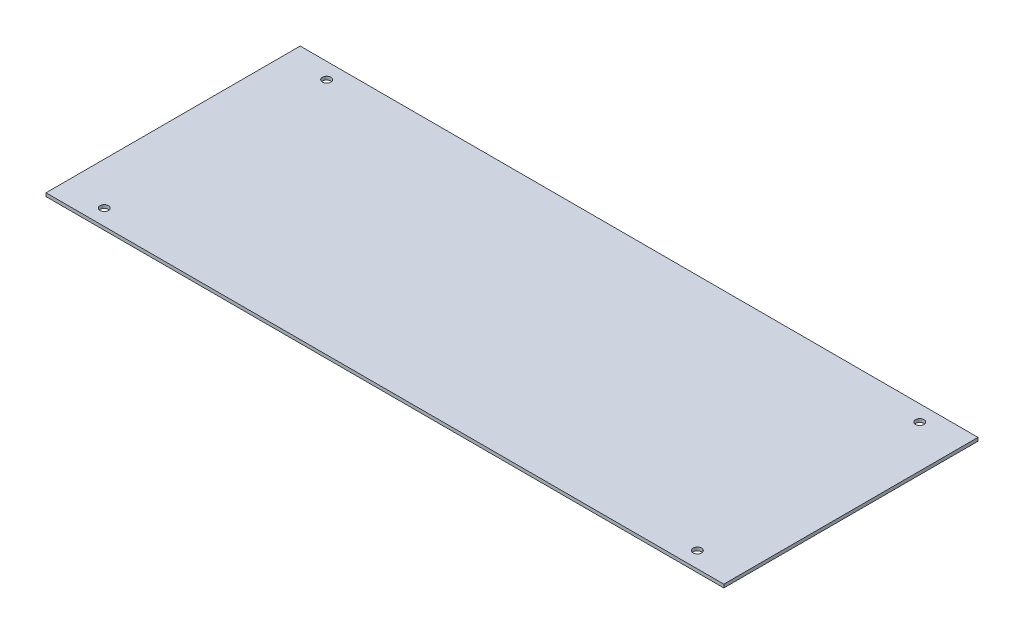
from build123d import *

# Parameters (mm, degrees)
SKETCH1_W           = 101.6
SKETCH1_H           = 38.1
SKETCH1_R           = 0.635
BOSS_EXTRUDE1_DEPTH = 0.5


with BuildPart() as part:
    # Sketch1 → Boss-Extrude1 (new body)
    with BuildSketch(Plane(origin=(0, 0, 0), x_dir=(1, 0, 0), z_dir=(0, 1, 0))):
        Rectangle(SKETCH1_W, SKETCH1_H)
        with Locations((44.45, 16.66875)):
            Circle(SKETCH1_R, mode=Mode.SUBTRACT)
        with Locations((44.45, -16.66875)):
            Circle(SKETCH1_R, mode=Mode.SUBTRACT)
        with Locations((-44.45, 16.66875)):
            Circle(SKETCH1_R, mode=Mode.SUBTRACT)
        with Locations((-44.45, -16.66875)):
            Circle(SKETCH1_R, mode=Mode.SUBTRACT)
    extrude(amount=BOSS_EXTRUDE1_DEPTH)


solid = part.part
